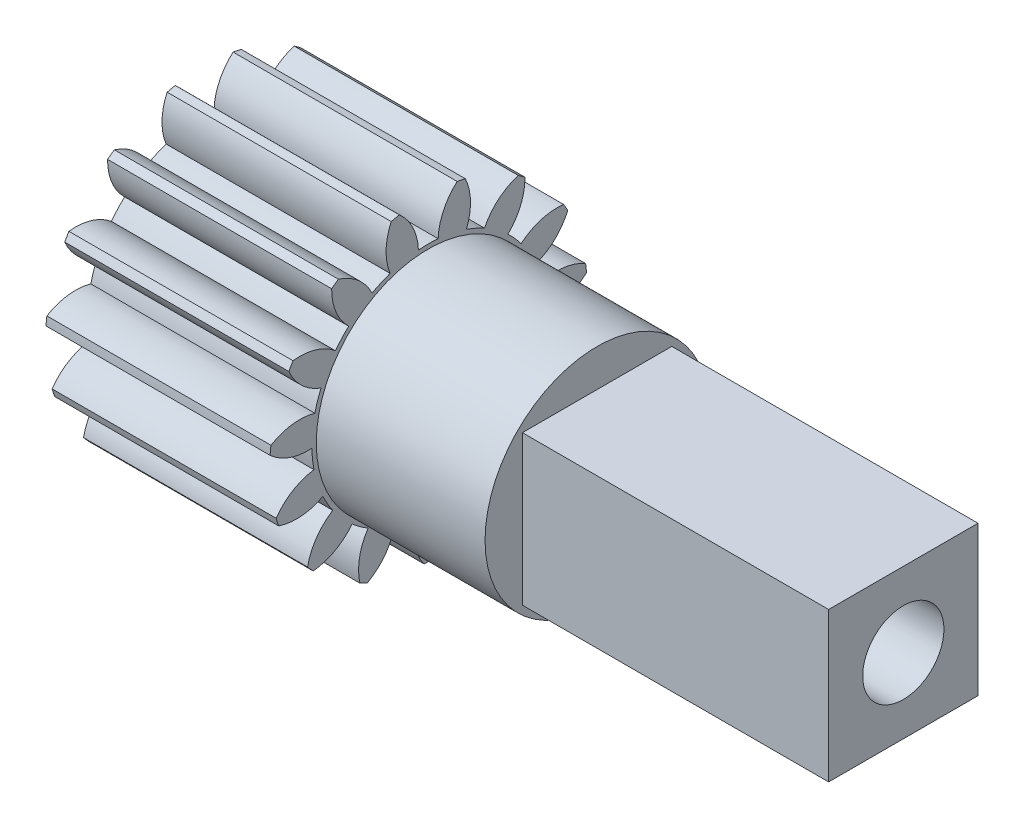
from build123d import *

# Parameters (mm, degrees)
SKETCH1_W                = 9.525
SKETCH1_H                = 6.746875
CUT_EXTRUDE1_DEPTH       = 10.525
CUT_EXTRUDE2_DEPTH       = 10.525
CUT_EXTRUDE3_DEPTH       = 10.525
CUT_EXTRUDE4_DEPTH       = 10.525
CUT_EXTRUDE5_DEPTH       = 10.525
CUT_EXTRUDE6_DEPTH       = 10.525
CUT_EXTRUDE7_DEPTH       = 10.525
CUT_EXTRUDE8_DEPTH       = 10.525
CUT_EXTRUDE9_DEPTH       = 10.525
CUT_EXTRUDE10_DEPTH      = 10.525
CUT_EXTRUDE11_DEPTH      = 10.525
CUT_EXTRUDE12_DEPTH      = 10.525
CUT_EXTRUDE13_DEPTH      = 10.525
CUT_EXTRUDE14_DEPTH      = 10.525
CUT_EXTRUDE15_DEPTH      = 10.525
SKETCH17_R               = 4.7625
BOSS_EXTRUDE1_DEPTH      = 7.1755
SKETCH18_W               = 6.35
SKETCH18_H               = 6.35
BOSS_EXTRUDE2_DEPTH      = 13.0175
M3_CLEARANCE_HOLE1_D     = 3.4544
M3_CLEARANCE_HOLE1_DEPTH = 16.93164
M3_CLEARANCE_HOLE1_TIP   = 1.037806461


with BuildPart() as part:
    # Sketch1 → Revolve1 (revolve)
    with BuildSketch(Plane(origin=(0, 0, 0), x_dir=(-1, 0, 0), z_dir=(0, 0, -1))):
        with Locations((-1.5875, 3.3734375)):
            Rectangle(SKETCH1_W, SKETCH1_H)
    revolve(axis=Axis((6.35, 0, 0), (-1, 0, 0)))

    # Sketch2 → Cut-Extrude1 (cut, through all)
    with BuildSketch(Plane(origin=(6.35, 0, 0), x_dir=(0, 0, -1), z_dir=(1, 0, 0))):
        with BuildLine():
            ThreePointArc((-4.893369276, -4.644917588), (-3.965713624, -5.458336534), (-2.905444874, -6.089229208))
            ThreePointArc((-2.905444874, -6.089229208), (-2.92382812, -5.1271904), (-2.559987212, -4.236417473))
            ThreePointArc((-2.559987212, -4.236417473), (-2.909434136, -4.004492544), (-3.23799289, -3.743817514))
            ThreePointArc((-3.23799289, -3.743817514), (-3.972735262, -4.365114753), (-4.893369276, -4.644917588))
        make_face()
    extrude(amount=-CUT_EXTRUDE1_DEPTH, mode=Mode.SUBTRACT)

    # Sketch3 → Cut-Extrude2 (cut, through all)
    with BuildSketch(Plane(origin=(6.35, 0, 0), x_dir=(0, 0, -1), z_dir=(1, 0, 0))):
        with BuildLine():
            ThreePointArc((-6.359573461, -2.253030771), (-5.842965146, -3.3734375), (-5.130968614, -4.381036789))
            ThreePointArc((-5.130968614, -4.381036789), (-4.75646611, -3.494693465), (-4.061770911, -2.828919335))
            ThreePointArc((-4.061770911, -2.828919335), (-4.286674194, -2.4749125), (-4.480801464, -2.103137126))
            ThreePointArc((-4.480801464, -2.103137126), (-5.404726374, -2.37187375), (-6.359573461, -2.253030771))
        make_face()
    extrude(amount=-CUT_EXTRUDE2_DEPTH, mode=Mode.SUBTRACT)

    # Sketch4 → Cut-Extrude3 (cut, through all)
    with BuildSketch(Plane(origin=(6.35, 0, 0), x_dir=(0, 0, -1), z_dir=(1, 0, 0))):
        with BuildLine():
            ThreePointArc((-6.726149621, 0.528425534), (-6.709914913, -0.705240476), (-6.469301267, -1.915323309))
            ThreePointArc((-6.469301267, -1.915323309), (-5.766667898, -1.257932283), (-4.861237519, -0.932275343))
            ThreePointArc((-4.861237519, -0.932275343), (-4.922709341, -0.517397601), (-4.948838759, -0.098805222))
            ThreePointArc((-4.948838759, -0.098805222), (-5.902191196, 0.031485771), (-6.726149621, 0.528425534))
        make_face()
    extrude(amount=-CUT_EXTRUDE3_DEPTH, mode=Mode.SUBTRACT)

    # Sketch5 → Cut-Extrude4 (cut, through all)
    with BuildSketch(Plane(origin=(6.35, 0, 0), x_dir=(0, 0, -1), z_dir=(1, 0, 0))):
        with BuildLine():
            ThreePointArc((-5.929713406, 3.218512264), (-6.416659433, 2.084899034), (-6.68903296, 0.881566972))
            ThreePointArc((-6.68903296, 0.881566972), (-5.779760418, 1.196336819), (-4.820151997, 1.125567525))
            ThreePointArc((-4.820151997, 1.125567525), (-4.707563321, 1.529580044), (-4.561176873, 1.922611002))
            ThreePointArc((-4.561176873, 1.922611002), (-5.37911354, 2.429401117), (-5.929713406, 3.218512264))
        make_face()
    extrude(amount=-CUT_EXTRUDE4_DEPTH, mode=Mode.SUBTRACT)

    # Sketch6 → Cut-Extrude5 (cut, through all)
    with BuildSketch(Plane(origin=(6.35, 0, 0), x_dir=(0, 0, -1), z_dir=(1, 0, 0))):
        with BuildLine():
            ThreePointArc((-5.752170086, 3.526026314), (-4.793479854, 3.443748417), (-3.945618406, 2.988789542))
            ThreePointArc((-3.945618406, 2.988789542), (-3.678436836, 3.312079404), (-3.384846069, 3.611590317))
            ThreePointArc((-3.384846069, 3.611590317), (-3.925938286, 4.40725094), (-4.107975873, 5.352088984))
            ThreePointArc((-4.107975873, 5.352088984), (-5.013905244, 4.51454056), (-5.752170086, 3.526026314))
        make_face()
    extrude(amount=-CUT_EXTRUDE5_DEPTH, mode=Mode.SUBTRACT)

    # Sketch7 → Cut-Extrude6 (cut, through all)
    with BuildSketch(Plane(origin=(6.35, 0, 0), x_dir=(0, 0, -1), z_dir=(1, 0, 0))):
        with BuildLine():
            ThreePointArc((-3.820704747, 5.560803674), (-2.978363076, 5.095704628), (-2.388851547, 4.335222695))
            ThreePointArc((-2.388851547, 4.335222695), (-2.013275204, 4.521890145), (-1.623244629, 4.676092857))
            ThreePointArc((-1.623244629, 4.676092857), (-1.793932636, 5.623047036), (-1.575931992, 6.560240897))
            ThreePointArc((-1.575931992, 6.560240897), (-2.744201289, 6.16357701), (-3.820704747, 5.560803674))
        make_face()
    extrude(amount=-CUT_EXTRUDE6_DEPTH, mode=Mode.SUBTRACT)

    # Sketch8 → Cut-Extrude7 (cut, through all)
    with BuildSketch(Plane(origin=(6.35, 0, 0), x_dir=(0, 0, -1), z_dir=(1, 0, 0))):
        with BuildLine():
            ThreePointArc((1.228604847, 6.63406756), (0, 6.746875), (-1.228604847, 6.63406756))
            ThreePointArc((-1.228604847, 6.63406756), (-0.648260265, 5.866567216), (-0.419030554, 4.93205646))
            ThreePointArc((-0.419030554, 4.93205646), (0, 4.949825), (0.419030554, 4.93205646))
            ThreePointArc((0.419030554, 4.93205646), (0.648260265, 5.866567216), (1.228604847, 6.63406756))
        make_face()
    extrude(amount=-CUT_EXTRUDE7_DEPTH, mode=Mode.SUBTRACT)

    # Sketch9 → Cut-Extrude8 (cut, through all)
    with BuildSketch(Plane(origin=(6.35, 0, 0), x_dir=(0, 0, -1), z_dir=(1, 0, 0))):
        with BuildLine():
            ThreePointArc((3.820704747, 5.560803674), (2.744201289, 6.16357701), (1.575931992, 6.560240897))
            ThreePointArc((1.575931992, 6.560240897), (1.793932636, 5.623047036), (1.623244629, 4.676092857))
            ThreePointArc((1.623244629, 4.676092857), (2.013275204, 4.521890145), (2.388851547, 4.335222695))
            ThreePointArc((2.388851547, 4.335222695), (2.978363076, 5.095704628), (3.820704747, 5.560803674))
        make_face()
    extrude(amount=-CUT_EXTRUDE8_DEPTH, mode=Mode.SUBTRACT)

    # Sketch10 → Cut-Extrude9 (cut, through all)
    with BuildSketch(Plane(origin=(6.35, 0, 0), x_dir=(0, 0, -1), z_dir=(1, 0, 0))):
        with BuildLine():
            ThreePointArc((5.752170086, 3.526026314), (5.013905244, 4.51454056), (4.107975873, 5.352088984))
            ThreePointArc((4.107975873, 5.352088984), (3.925938286, 4.40725094), (3.384846069, 3.611590317))
            ThreePointArc((3.384846069, 3.611590317), (3.678436836, 3.312079404), (3.945618406, 2.988789542))
            ThreePointArc((3.945618406, 2.988789542), (4.793479854, 3.443748417), (5.752170086, 3.526026314))
        make_face()
    extrude(amount=-CUT_EXTRUDE9_DEPTH, mode=Mode.SUBTRACT)

    # Sketch11 → Cut-Extrude10 (cut, through all)
    with BuildSketch(Plane(origin=(6.35, 0, 0), x_dir=(0, 0, -1), z_dir=(1, 0, 0))):
        with BuildLine():
            ThreePointArc((6.68903296, 0.881566972), (6.416659433, 2.084899034), (5.929713406, 3.218512264))
            ThreePointArc((5.929713406, 3.218512264), (5.37911354, 2.429401117), (4.561176873, 1.922611002))
            ThreePointArc((4.561176873, 1.922611002), (4.707563321, 1.529580044), (4.820151997, 1.125567525))
            ThreePointArc((4.820151997, 1.125567525), (5.779760418, 1.196336819), (6.68903296, 0.881566972))
        make_face()
    extrude(amount=-CUT_EXTRUDE10_DEPTH, mode=Mode.SUBTRACT)

    # Sketch12 → Cut-Extrude11 (cut, through all)
    with BuildSketch(Plane(origin=(6.35, 0, 0), x_dir=(0, 0, -1), z_dir=(1, 0, 0))):
        with BuildLine():
            ThreePointArc((6.469301267, -1.915323309), (6.709914913, -0.705240476), (6.726149621, 0.528425534))
            ThreePointArc((6.726149621, 0.528425534), (5.902191196, 0.031485771), (4.948838759, -0.098805222))
            ThreePointArc((4.948838759, -0.098805222), (4.922709341, -0.517397601), (4.861237519, -0.932275343))
            ThreePointArc((4.861237519, -0.932275343), (5.766667898, -1.257932283), (6.469301267, -1.915323309))
        make_face()
    extrude(amount=-CUT_EXTRUDE11_DEPTH, mode=Mode.SUBTRACT)

    # Sketch13 → Cut-Extrude12 (cut, through all)
    with BuildSketch(Plane(origin=(6.35, 0, 0), x_dir=(0, 0, -1), z_dir=(1, 0, 0))):
        with BuildLine():
            ThreePointArc((5.130968614, -4.381036789), (5.842965146, -3.3734375), (6.359573461, -2.253030771))
            ThreePointArc((6.359573461, -2.253030771), (5.404726374, -2.37187375), (4.480801464, -2.103137126))
            ThreePointArc((4.480801464, -2.103137126), (4.286674194, -2.4749125), (4.061770911, -2.828919335))
            ThreePointArc((4.061770911, -2.828919335), (4.75646611, -3.494693465), (5.130968614, -4.381036789))
        make_face()
    extrude(amount=-CUT_EXTRUDE12_DEPTH, mode=Mode.SUBTRACT)

    # Sketch14 → Cut-Extrude13 (cut, through all)
    with BuildSketch(Plane(origin=(6.35, 0, 0), x_dir=(0, 0, -1), z_dir=(1, 0, 0))):
        with BuildLine():
            ThreePointArc((2.905444874, -6.089229208), (3.965713624, -5.458336534), (4.893369276, -4.644917588))
            ThreePointArc((4.893369276, -4.644917588), (3.972735262, -4.365114753), (3.23799289, -3.743817514))
            ThreePointArc((3.23799289, -3.743817514), (2.909434136, -4.004492544), (2.559987212, -4.236417473))
            ThreePointArc((2.559987212, -4.236417473), (2.92382812, -5.1271904), (2.905444874, -6.089229208))
        make_face()
    extrude(amount=-CUT_EXTRUDE13_DEPTH, mode=Mode.SUBTRACT)

    # Sketch15 → Cut-Extrude14 (cut, through all)
    with BuildSketch(Plane(origin=(6.35, 0, 0), x_dir=(0, 0, -1), z_dir=(1, 0, 0))):
        with BuildLine():
            ThreePointArc((0.17754332, -6.744538578), (1.402754189, -6.599439594), (2.581057087, -6.233655956))
            ThreePointArc((2.581057087, -6.233655956), (1.853822132, -5.603587759), (1.435305929, -4.737157842))
            ThreePointArc((1.435305929, -4.737157842), (1.029126485, -4.841659448), (0.615558467, -4.911400544))
            ThreePointArc((0.615558467, -4.911400544), (0.585633687, -5.873149535), (0.17754332, -6.744538578))
        make_face()
    extrude(amount=-CUT_EXTRUDE14_DEPTH, mode=Mode.SUBTRACT)

    # Sketch16 → Cut-Extrude15 (cut, through all)
    with BuildSketch(Plane(origin=(6.35, 0, 0), x_dir=(0, 0, -1), z_dir=(1, 0, 0))):
        with BuildLine():
            ThreePointArc((-2.581057087, -6.233655956), (-1.402754189, -6.599439594), (-0.17754332, -6.744538578))
            ThreePointArc((-0.17754332, -6.744538578), (-0.585633687, -5.873149535), (-0.615558467, -4.911400544))
            ThreePointArc((-0.615558467, -4.911400544), (-1.029126485, -4.841659448), (-1.435305929, -4.737157842))
            ThreePointArc((-1.435305929, -4.737157842), (-1.853822132, -5.603587759), (-2.581057087, -6.233655956))
        make_face()
    extrude(amount=-CUT_EXTRUDE15_DEPTH, mode=Mode.SUBTRACT)

    # Sketch17 → Boss-Extrude1 (add)
    with BuildSketch(Plane(origin=(6.35, 0, 0), x_dir=(0, 0, -1), z_dir=(1, 0, 0))):
        Circle(SKETCH17_R)
    extrude(amount=BOSS_EXTRUDE1_DEPTH)

    # Sketch18 → Boss-Extrude2 (add)
    with BuildSketch(Plane(origin=(13.5255, 0, 0), x_dir=(0, 0, -1), z_dir=(1, 0, 0))):
        Rectangle(SKETCH18_W, SKETCH18_H)
    extrude(amount=BOSS_EXTRUDE2_DEPTH)

    # M3 Clearance Hole1
    with Locations(Plane(origin=(26.543, 0, 0), x_dir=(0, 0, -1), z_dir=(1, 0, 0))):
        with Locations((0, 0)):
            Hole(M3_CLEARANCE_HOLE1_D / 2, depth=M3_CLEARANCE_HOLE1_DEPTH)
            with Locations((0, 0, -(M3_CLEARANCE_HOLE1_DEPTH + M3_CLEARANCE_HOLE1_TIP / 2))):  # 118° drill point
                Cone(0, M3_CLEARANCE_HOLE1_D / 2, M3_CLEARANCE_HOLE1_TIP, mode=Mode.SUBTRACT)


solid = part.part
